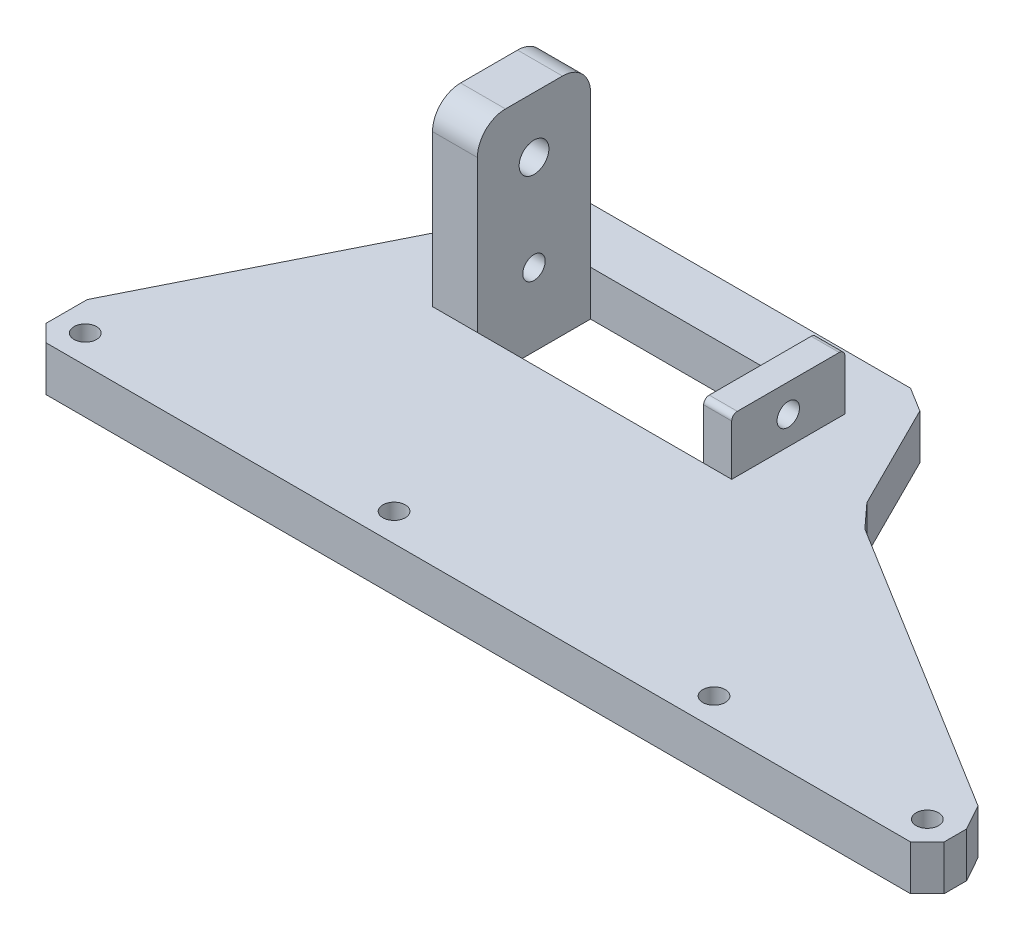
from build123d import *

# Parameters (mm, degrees)
CROQUIS1_R              = 2
CROQUIS1_W              = 53.3
CROQUIS1_H              = 20.15
SALIENTE_EXTRUIR1_DEPTH = 8
CROQUIS2_W              = 8
CROQUIS2_H              = 20.15
CROQUIS2_W_2            = 5
SALIENTE_EXTRUIR2_DEPTH = 8
CROQUIS2_4_W            = 5
CROQUIS2_4_H            = 20.15
SALIENTE_EXTRUIR3_DEPTH = 10
CROQUIS2_5_W            = 8
CROQUIS2_5_H            = 20.15
SALIENTE_EXTRUIR4_DEPTH = 32
CROQUIS4_R              = 2
CORTAR_EXTRUIR1_DEPTH   = 32
CORTAR_EXTRUIR2_START   = 74
CROQUIS4_2_R            = 2
CORTAR_EXTRUIR2_DEPTH   = 74
CROQUIS5_R              = 2.65
CORTAR_EXTRUIR3_DEPTH   = 35
CORTAR_EXTRUIR4_DEPTH   = 16
CORTAR_EXTRUIR5_DEPTH   = 16


with BuildPart() as part:
    # Croquis1 → Saliente-Extruir1 (new body)
    with BuildSketch(Plane(origin=(0, 0, 0), x_dir=(1, 0, 0), z_dir=(0, 1, 0))):
        Polygon((154, 0), (156.998132752, 2.998132752), (156.998132752, 6.998132752), (154.446539538, 11.574918968), (101.665094886, 44.198861104), (97.772883017, 48.458390041), (88.347282669, 67.313746258), (84.009081739, 69.99516616), (26.841381739, 69.99516616), (-2.995601596, 10.334082852), (-2.995601596, 3.004082852), (0, 0), align=None)
        with Locations((2, 4.998132752)):
            Circle(CROQUIS1_R, mode=Mode.SUBTRACT)
        with Locations((57, 4.998132752)):
            Circle(CROQUIS1_R, mode=Mode.SUBTRACT)
        with Locations((114, 4.998132752)):
            Circle(CROQUIS1_R, mode=Mode.SUBTRACT)
        with Locations((152, 4.998132752)):
            Circle(CROQUIS1_R, mode=Mode.SUBTRACT)
        with Locations((55.5, 50.075)):
            Rectangle(CROQUIS1_W, CROQUIS1_H, mode=Mode.SUBTRACT)
    extrude(amount=SALIENTE_EXTRUIR1_DEPTH)

    # Croquis2 → Saliente-Extruir2 (add)
    with BuildSketch(Plane(origin=(0, 8, 0), x_dir=(1, 0, 0), z_dir=(0, 1, 0))):
        with Locations((32.85, 50.075)):
            Rectangle(CROQUIS2_W, CROQUIS2_H)
        with Locations((79.65, 50.075)):
            Rectangle(CROQUIS2_W_2, CROQUIS2_H)
    extrude(amount=-SALIENTE_EXTRUIR2_DEPTH)

    # Croquis2_4 → Saliente-Extruir3 (add)
    with BuildSketch(Plane(origin=(0, 8, 0), x_dir=(1, 0, 0), z_dir=(0, 1, 0))):
        with Locations((79.65, 50.075)):
            Rectangle(CROQUIS2_4_W, CROQUIS2_4_H)
    extrude(amount=SALIENTE_EXTRUIR3_DEPTH)

    # Croquis2_5 → Saliente-Extruir4 (add)
    with BuildSketch(Plane(origin=(0, 8, 0), x_dir=(1, 0, 0), z_dir=(0, 1, 0))):
        with Locations((32.85, 50.075)):
            Rectangle(CROQUIS2_5_W, CROQUIS2_5_H)
    extrude(amount=SALIENTE_EXTRUIR4_DEPTH)

    # Croquis4 → Cortar-Extruir1 (cut)
    with BuildSketch(Plane.ZY.offset(-77.15)):
        with Locations((-50.075, 13)):
            Circle(CROQUIS4_R)
    extrude(amount=-CORTAR_EXTRUIR1_DEPTH, mode=Mode.SUBTRACT)

    # Croquis4_2 → Cortar-Extruir2 (cut)
    with BuildSketch(Plane.ZY.offset(-77.15).offset(CORTAR_EXTRUIR2_START)):
        with Locations((-50.075, 13)):
            Circle(CROQUIS4_2_R)
    extrude(amount=-CORTAR_EXTRUIR2_DEPTH, mode=Mode.SUBTRACT)

    # Croquis5 → Cortar-Extruir3 (cut)
    with BuildSketch(Plane(origin=(36.85, 0, 0), x_dir=(0, 0, -1), z_dir=(1, 0, 0))):
        with Locations((50.08, 30)):
            Circle(CROQUIS5_R)
    extrude(amount=-CORTAR_EXTRUIR3_DEPTH, mode=Mode.SUBTRACT)

    # Croquis6 → Cortar-Extruir4 (cut)
    with BuildSketch(Plane(origin=(82.15, 0, 0), x_dir=(0, 0, -1), z_dir=(1, 0, 0))):
        with BuildLine():
            Line((40, 17), (40, 18))
            Line((40, 18), (41, 18))
            ThreePointArc((41, 18), (40.292893219, 17.707106781), (40, 17))
        make_face()
        with BuildLine():
            Line((59.15, 18), (60.15, 18))
            Line((60.15, 18), (60.15, 17))
            ThreePointArc((60.15, 17), (59.857106781, 17.707106781), (59.15, 18))
        make_face()
    extrude(amount=-CORTAR_EXTRUIR4_DEPTH, mode=Mode.SUBTRACT)

    # Croquis7 → Cortar-Extruir5 (cut)
    with BuildSketch(Plane(origin=(36.85, 0, 0), x_dir=(0, 0, -1), z_dir=(1, 0, 0))):
        with BuildLine():
            Line((40, 35), (40, 40))
            Line((40, 40), (45, 40))
            ThreePointArc((45, 40), (41.464466094, 38.535533906), (40, 35))
        make_face()
        with BuildLine():
            Line((55.15, 40), (60.15, 40))
            Line((60.15, 40), (60.15, 35))
            ThreePointArc((60.15, 35), (58.685533906, 38.535533906), (55.15, 40))
        make_face()
    extrude(amount=-CORTAR_EXTRUIR5_DEPTH, mode=Mode.SUBTRACT)


solid = part.part
